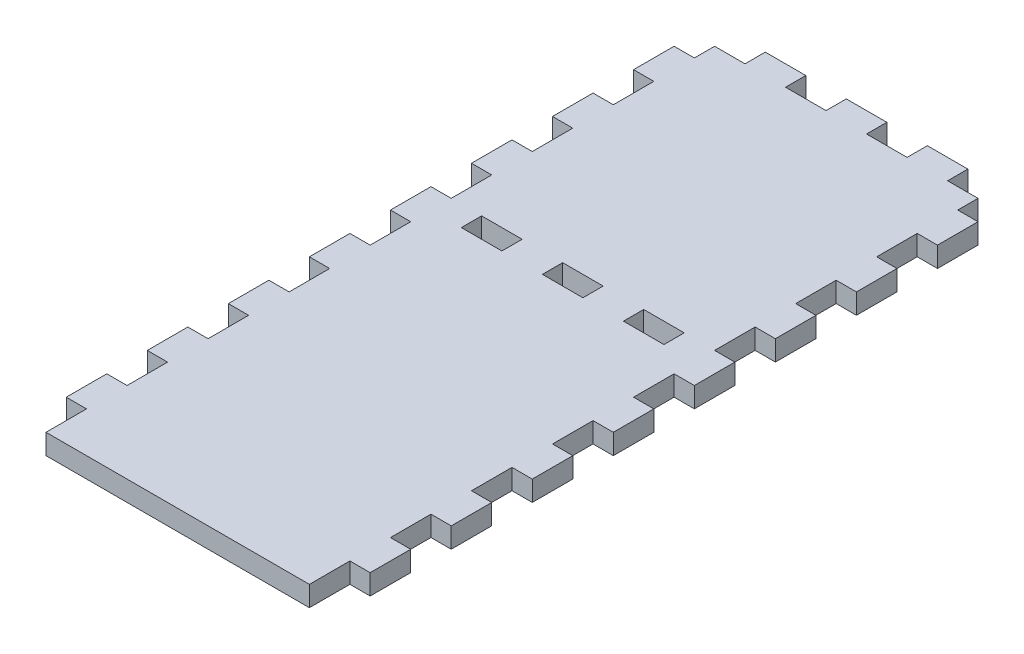
from build123d import *

# Parameters (mm, degrees)
SKETCH1_W           = 95.25
SKETCH1_H           = 215.9
BOSS_EXTRUDE1_DEPTH = 6.35
SKETCH2_W           = 6.35
SKETCH2_H           = 12.7
CUT_EXTRUDE1_DEPTH  = 7.35
LPATTERN1_COUNT     = 10
LPATTERN1_PITCH     = 25.4
SKETCH3_W           = 12.7
SKETCH3_H           = 6.35
CUT_EXTRUDE2_DEPTH  = 7.35
LPATTERN2_COUNT     = 2
LPATTERN2_PITCH     = 25.4
LPATTERN2_COL_COUNT = 3
LPATTERN2_COL_PITCH = 25.4
SKETCH4_W           = 12.7
SKETCH4_H           = 6.35
CUT_EXTRUDE3_DEPTH  = 7.35


with BuildPart() as part:
    # Sketch1 → Boss-Extrude1 (new body)
    with BuildSketch(Plane(origin=(0, 0, 0), x_dir=(1, 0, 0), z_dir=(0, 1, 0))):
        with Locations((47.625, 107.95)):
            Rectangle(SKETCH1_W, SKETCH1_H)
    extrude(amount=BOSS_EXTRUDE1_DEPTH)

    # Sketch2 → Cut-Extrude1 (cut, through all)
    with BuildSketch(Plane(origin=(0, 6.35, 0), x_dir=(1, 0, 0), z_dir=(0, 1, 0))):
        with Locations((3.175, 209.55)):
            Rectangle(SKETCH2_W, SKETCH2_H)
        with Locations((92.075, 209.55)):
            Rectangle(SKETCH2_W, SKETCH2_H)
    cut_extrude1 = extrude(amount=-CUT_EXTRUDE1_DEPTH, mode=Mode.SUBTRACT)

    # LPattern1: Cut-Extrude1 ×10
    with Locations(*[(0, 0, i * LPATTERN1_PITCH) for i in range(1, LPATTERN1_COUNT)]):
        add(cut_extrude1, mode=Mode.SUBTRACT)

    # Sketch3 → Cut-Extrude2 (cut, through all)
    with BuildSketch(Plane(origin=(0, 6.35, 0), x_dir=(1, 0, 0), z_dir=(0, 1, 0))):
        with Locations((34.925, 212.725)):
            Rectangle(SKETCH3_W, SKETCH3_H)
    cut_extrude2 = extrude(amount=-CUT_EXTRUDE2_DEPTH, mode=Mode.SUBTRACT)

    # LPattern2: Cut-Extrude2 ×2
    with Locations(*[(-i * LPATTERN2_PITCH, 0, 0) for i in range(1, LPATTERN2_COUNT)]):
        add(cut_extrude2, mode=Mode.SUBTRACT)

    # LPattern2 col: Cut-Extrude2 ×3
    with Locations(*[(i * LPATTERN2_COL_PITCH, 0, 0) for i in range(1, LPATTERN2_COL_COUNT)]):
        add(cut_extrude2, mode=Mode.SUBTRACT)

    # Sketch4 → Cut-Extrude3 (cut, through all)
    with BuildSketch(Plane(origin=(0, 6.35, 0), x_dir=(1, 0, 0), z_dir=(0, 1, 0))):
        with Locations((22.225, 123.825)):
            Rectangle(SKETCH4_W, SKETCH4_H)
        with Locations((47.625, 123.825)):
            Rectangle(SKETCH4_W, SKETCH4_H)
        with Locations((73.025, 123.825)):
            Rectangle(SKETCH4_W, SKETCH4_H)
    extrude(amount=-CUT_EXTRUDE3_DEPTH, mode=Mode.SUBTRACT)


solid = part.part
